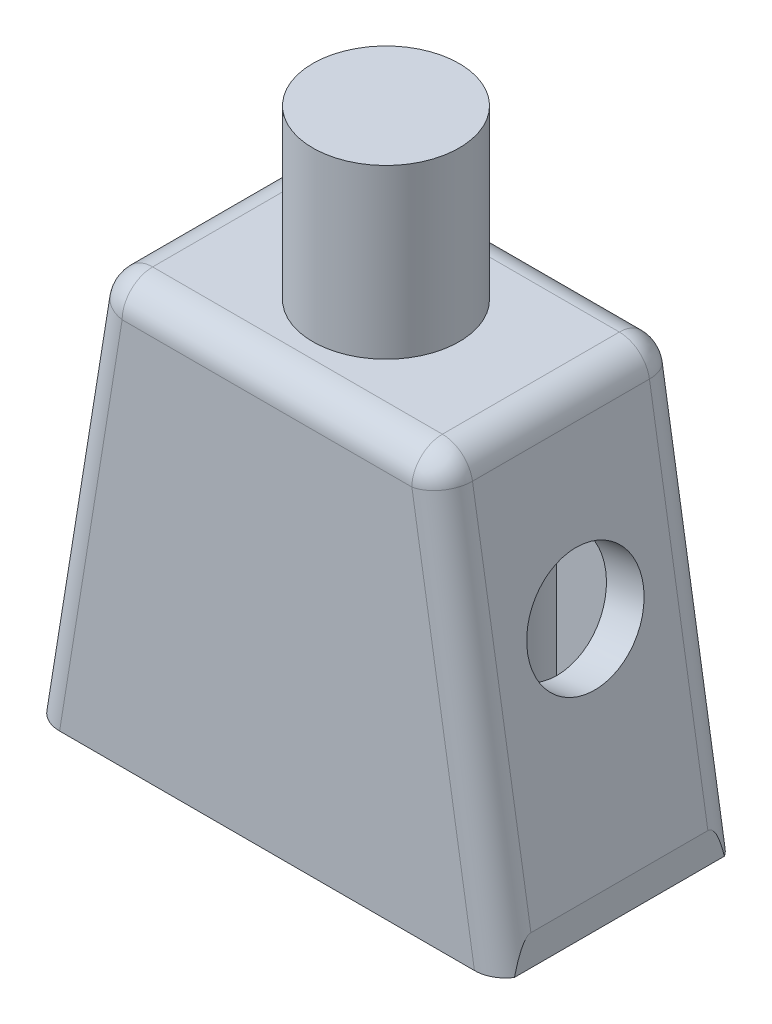
from build123d import *

# Parameters (mm, degrees)
BOSS_EXTRUDE1_DEPTH = 3.9
SHELL5_T            = -1.25
SKETCH2_R           = 2.4
BOSS_EXTRUDE2_DEPTH = 5.5
BOSS_EXTRUDE3_DEPTH = 12.45
SKETCH6_R           = 0.7
CUT_EXTRUDE2_DEPTH  = 4.25
CUT_EXTRUDE3_REACH  = 17.264
SKETCH7_R           = 1.9
CUT_EXTRUDE4_REACH  = 17.264
SKETCH8_R           = 1.9
FILLET1_R           = 1


with BuildPart() as part:
    # Sketch1 → Boss-Extrude1 (new body, symmetric)
    with BuildSketch(Plane.XY):
        Polygon((-7.65, -5.85), (-7.65, -6.85), (7.65, -6.85), (7.65, -5.85), (5.599872407, 6.85), (-5.600127593, 6.85), align=None)
    extrude(amount=BOSS_EXTRUDE1_DEPTH, both=True)

    # Shell5
    shell5_openings = [part.faces().sort_by_distance(p)[0] for p in [
        (0, -6.85, 0),
    ]]
    offset(amount=SHELL5_T, openings=shell5_openings, kind=Kind.INTERSECTION)

    # Sketch2 → Boss-Extrude2 (add)
    with BuildSketch(Plane(origin=(0, 6.85, 0), x_dir=(1, 0, 0), z_dir=(0, 1, 0))):
        Circle(SKETCH2_R)
    extrude(amount=BOSS_EXTRUDE2_DEPTH)

    # Sketch5 → Boss-Extrude3 (add, through all)
    with BuildSketch(Plane.XZ.offset(-5.6)):
        with BuildLine():
            Line((-1.5, 1.25), (-1.5, 2.65))
            Line((-1.5, 2.65), (-2.9, 2.65))
            ThreePointArc((-2.9, 2.65), (-2.489949494, 1.660050506), (-1.5, 1.25))
        make_face()
        with BuildLine():
            Line((1.530768156, 2.65), (1.530768156, 1.25))
            ThreePointArc((1.530768156, 1.25), (2.52071765, 1.660050506), (2.930768156, 2.65))
            Line((2.930768156, 2.65), (1.530768156, 2.65))
        make_face()
        with BuildLine():
            Line((-1.5, -1.25), (-1.5, -2.65))
            Line((-1.5, -2.65), (-2.9, -2.65))
            ThreePointArc((-2.9, -2.65), (-2.489949494, -1.660050506), (-1.5, -1.25))
        make_face()
        with BuildLine():
            Line((1.530768156, -2.65), (1.530768156, -1.25))
            ThreePointArc((1.530768156, -1.25), (2.52071765, -1.660050506), (2.930768156, -2.65))
            Line((2.930768156, -2.65), (1.530768156, -2.65))
        make_face()
    extrude(amount=BOSS_EXTRUDE3_DEPTH)

    # Sketch6 → Cut-Extrude2 (cut)
    with BuildSketch(Plane.XZ.offset(-5.6)):
        Circle(SKETCH6_R)
    extrude(amount=-CUT_EXTRUDE2_DEPTH, mode=Mode.SUBTRACT)

    # Sketch7 → Cut-Extrude3 (cut, up to next)
    with BuildSketch(Plane(origin=(6.535346626, 1.054983815, 0), x_dir=(0, 0, -1), z_dir=(0.987219843, 0.159364302, 0)), mode=Mode.PRIVATE) as cut_extrude3_sk1:
        Circle(SKETCH7_R)
    cut_extrude3_tool1 = extrude(cut_extrude3_sk1.sketch, amount=-CUT_EXTRUDE3_REACH, mode=Mode.PRIVATE) & part.part
    add(cut_extrude3_tool1.solids().sort_by_distance((6.535347, 1.054984, 0))[0], mode=Mode.SUBTRACT)

    # Sketch8 → Cut-Extrude4 (cut, up to next)
    with BuildSketch(Plane(origin=(-6.535502505, 1.054877658, 0), x_dir=(0, 0, 1), z_dir=(-0.987222964, 0.15934497, 0)), mode=Mode.PRIVATE) as cut_extrude4_sk1:
        Circle(SKETCH8_R)
    cut_extrude4_tool1 = extrude(cut_extrude4_sk1.sketch, amount=-CUT_EXTRUDE4_REACH, mode=Mode.PRIVATE) & part.part
    add(cut_extrude4_tool1.solids().sort_by_distance((-6.535503, 1.054878, 0))[0], mode=Mode.SUBTRACT)

    # Fillet1
    fillet1_edges = [part.edges().sort_by_distance(p)[0] for p in [
        (-6.625063797, 0.5, -3.9),
        (6.624936203, 0.5, -3.9),
        (-0.000127593, 6.85, -3.9),
        (-5.600127593, 6.85, 0),
        (-6.625063797, 0.5, 3.9),
        (-0.000127593, 6.85, 3.9),
        (6.624936203, 0.5, 3.9),
        (5.599872407, 6.85, 0),
    ]]
    fillet(fillet1_edges, radius=FILLET1_R)


solid = part.part
